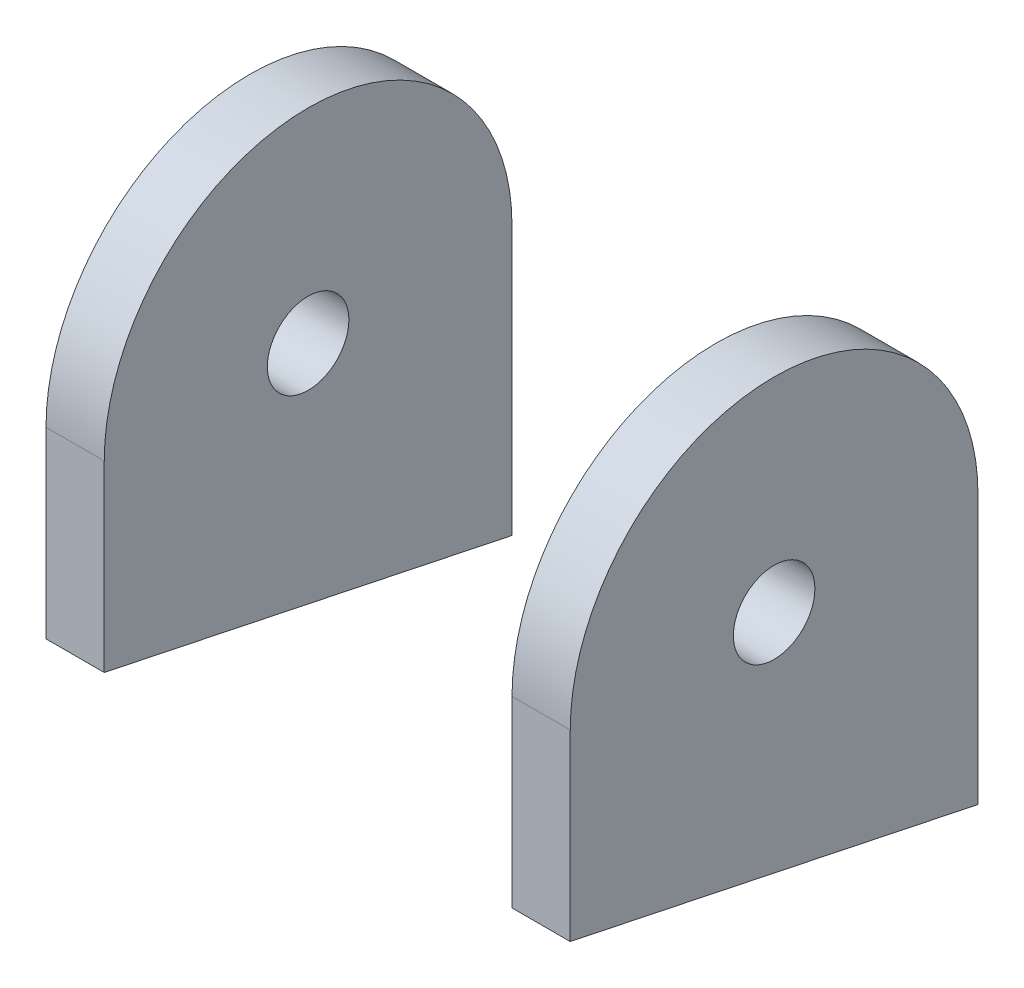
from build123d import *

# Parameters (mm, degrees)
EXTRUDE_1_DEPTH      = 10
EXTRUDE_1_DEPTH_BACK = 80
SKETCH_1_R           = 7
CUT_EXTRUDE_START    = -70
SKETCH_1_2_R         = 7
CUT_EXTRUDE_1_DEPTH  = 70
SKETCH_2_R           = 199.366256812
CUT_EXTRUDE_4_DEPTH  = 284.687476453


with BuildPart() as part:
    # 草图1 → 凸台-拉伸1 (new, two sides: drawn at the far end of the back side and taken through both)
    with BuildSketch(Plane(origin=(0, 0, 0), x_dir=(0, 0, -1), z_dir=(1, 0, 0)).offset(-EXTRUDE_1_DEPTH_BACK)):
        with BuildLine():
            Line((35, 0), (35, -100))
            Line((35, -100), (-35, -100))
            Line((-35, -100), (-35, 0))
            ThreePointArc((-35, 0), (0, 35), (35, 0))
        make_face()
        Circle(SKETCH_1_R, mode=Mode.SUBTRACT)
    extrude(amount=EXTRUDE_1_DEPTH + EXTRUDE_1_DEPTH_BACK)

    # 草图1<2> → 切除-拉伸1 (cut)
    with BuildSketch(Plane(origin=(0, 0, 0), x_dir=(0, 0, -1), z_dir=(1, 0, 0)).offset(CUT_EXTRUDE_START)):
        with BuildLine():
            Line((35, 0), (35, -100))
            Line((35, -100), (-35, -100))
            Line((-35, -100), (-35, 0))
            ThreePointArc((-35, 0), (0, 35), (35, 0))
        make_face()
        Circle(SKETCH_1_2_R, mode=Mode.SUBTRACT)
    extrude(amount=CUT_EXTRUDE_1_DEPTH, mode=Mode.SUBTRACT)


with BuildPart() as cut_extrude_1_piece_1:
    # of the separate pieces the step leaves, piece 1, a body of its own (cut_extrude_1_pieces)
    add(part.part.solids().sort_by_distance((0, 0, -35))[0])


with BuildPart() as cut_extrude_1_piece_2:
    # of the separate pieces the step leaves, piece 2, a body of its own (cut_extrude_1_pieces)
    add(part.part.solids().sort_by_distance((-80, 0, -35))[0])


with BuildPart() as cut_extrude_4_tool:
    # 草图2 → 切除-拉伸4 (new body)
    with BuildSketch(Plane(origin=(0, -37.143957238, 7.762028428), x_dir=(-1, 0, 0), z_dir=(0, 0.9788555101327263, -0.20455290338394244))):
        Circle(SKETCH_2_R)
    extrude(amount=-CUT_EXTRUDE_4_DEPTH)


with BuildPart() as cut_extrude_1_piece_1_1:
    add(cut_extrude_1_piece_1.part)

    # 切除-拉伸4: cut by cut_extrude_4_tool
    add(cut_extrude_4_tool.part, mode=Mode.SUBTRACT)


with BuildPart() as cut_extrude_1_piece_2_1:
    add(cut_extrude_1_piece_2.part)

    # 切除-拉伸4: cut by cut_extrude_4_tool
    add(cut_extrude_4_tool.part, mode=Mode.SUBTRACT)


solid = Compound([cut_extrude_1_piece_1_1.part, cut_extrude_1_piece_2_1.part])
